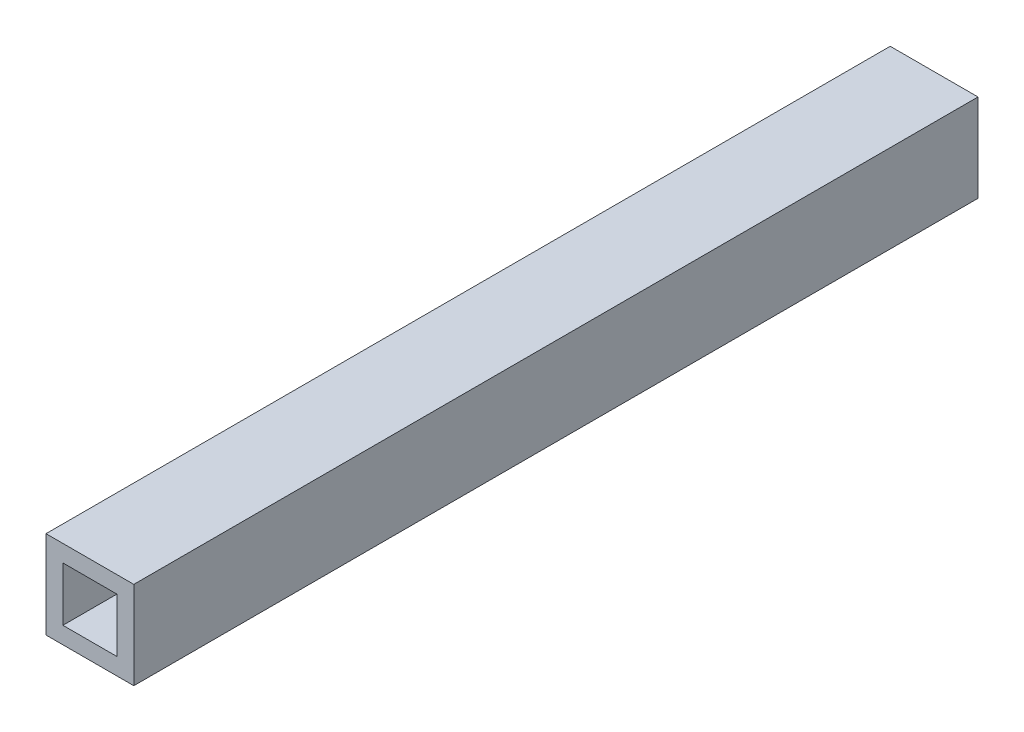
from build123d import *

# Parameters (mm, degrees)
SKETCH1_W           = 1.04
SKETCH1_H           = 1.04
SKETCH1_W_2         = 0.64
SKETCH1_H_2         = 0.64
BOSS_EXTRUDE1_DEPTH = 10


with BuildPart() as part:
    # Sketch1 → Boss-Extrude1 (new body)
    with BuildSketch(Plane.XY):
        with Locations((-18.867292231, -16.690812939)):
            Rectangle(SKETCH1_W, SKETCH1_H)
        with Locations((-18.867292231, -16.690812939)):
            Rectangle(SKETCH1_W_2, SKETCH1_H_2, mode=Mode.SUBTRACT)
    extrude(amount=BOSS_EXTRUDE1_DEPTH)


solid = part.part
